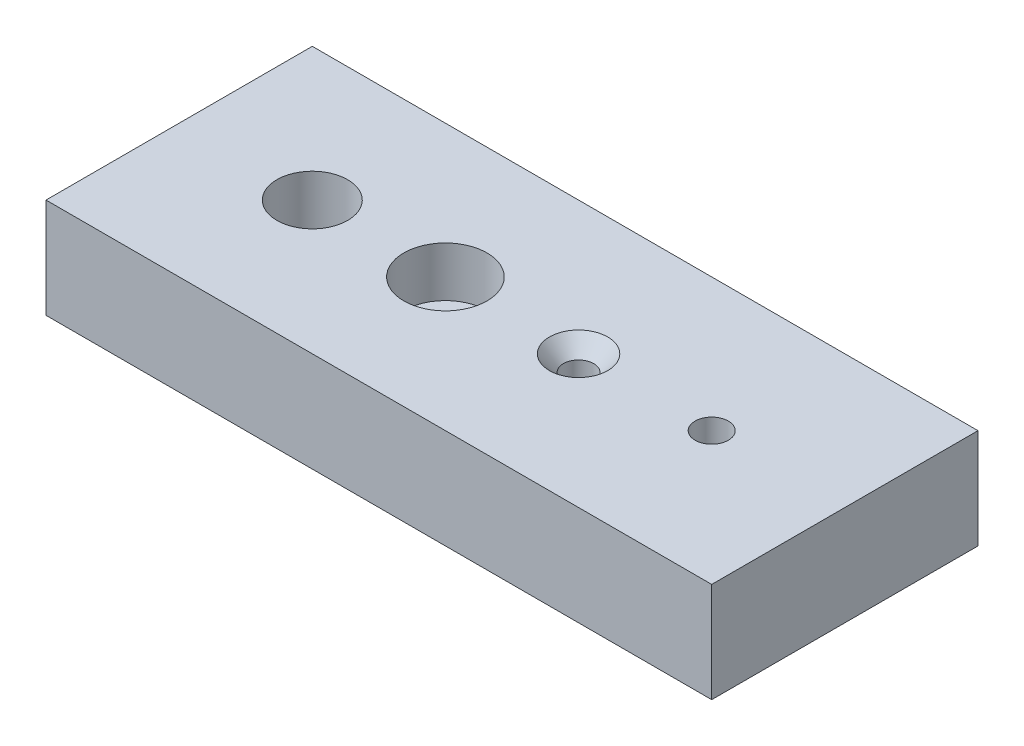
from build123d import *

# Parameters (mm, degrees)
SKETCH1_W                                        = 127
SKETCH1_H                                        = 19.05
BOSS_EXTRUDE1_DEPTH                              = 50.8
F_1_2_CLEARANCE_HOLE1_D                          = 13.49248
CBORE_FOR_3_8_SOCKET_HEAD_CAP_SCREW1_D           = 9.8044
CBORE_FOR_3_8_SOCKET_HEAD_CAP_SCREW1_CBORE_D     = 15.875
CBORE_FOR_3_8_SOCKET_HEAD_CAP_SCREW1_CBORE_DEPTH = 9.525
CSK_FOR_12_FLAT_HEAD_MACHINE_SCREW1_D            = 5.7912
CSK_FOR_12_FLAT_HEAD_MACHINE_SCREW1_CSINK_D      = 11.1252
CSK_FOR_12_FLAT_HEAD_MACHINE_SCREW1_CSINK_ANGLE  = 82
F_1_4_0_2500_DOWEL_HOLE1_D                       = 6.35


with BuildPart() as part:
    # Sketch1 → Boss-Extrude1 (new body)
    with BuildSketch(Plane.XY):
        with Locations((63.5, 9.525)):
            Rectangle(SKETCH1_W, SKETCH1_H)
    extrude(amount=BOSS_EXTRUDE1_DEPTH)

    # 1/2 Clearance Hole1 (through all)
    with Locations(Plane(origin=(0, 19.05, 0), x_dir=(1, 0, 0), z_dir=(0, 1, 0))):
        with Locations((25.4, -25.4)):
            Hole(F_1_2_CLEARANCE_HOLE1_D / 2)

    # CBORE for 3/8 Socket Head Cap Screw1 (through all)
    with Locations(Plane(origin=(0, 19.05, 0), x_dir=(1, 0, 0), z_dir=(0, 1, 0))):
        with Locations((50.8, -25.4)):
            CounterBoreHole(CBORE_FOR_3_8_SOCKET_HEAD_CAP_SCREW1_D / 2, CBORE_FOR_3_8_SOCKET_HEAD_CAP_SCREW1_CBORE_D / 2, CBORE_FOR_3_8_SOCKET_HEAD_CAP_SCREW1_CBORE_DEPTH)

    # CSK for #12 Flat Head Machine Screw1 (through all)
    with Locations(Plane(origin=(0, 19.05, 0), x_dir=(1, 0, 0), z_dir=(0, 1, 0))):
        with Locations((76.2, -25.4)):
            CounterSinkHole(CSK_FOR_12_FLAT_HEAD_MACHINE_SCREW1_D / 2, CSK_FOR_12_FLAT_HEAD_MACHINE_SCREW1_CSINK_D / 2, counter_sink_angle=CSK_FOR_12_FLAT_HEAD_MACHINE_SCREW1_CSINK_ANGLE)

    # 1/4 (0.2500) Dowel Hole1 (through all)
    with Locations(Plane(origin=(0, 19.05, 0), x_dir=(1, 0, 0), z_dir=(0, 1, 0))):
        with Locations((101.6, -25.4)):
            Hole(F_1_4_0_2500_DOWEL_HOLE1_D / 2)


solid = part.part
